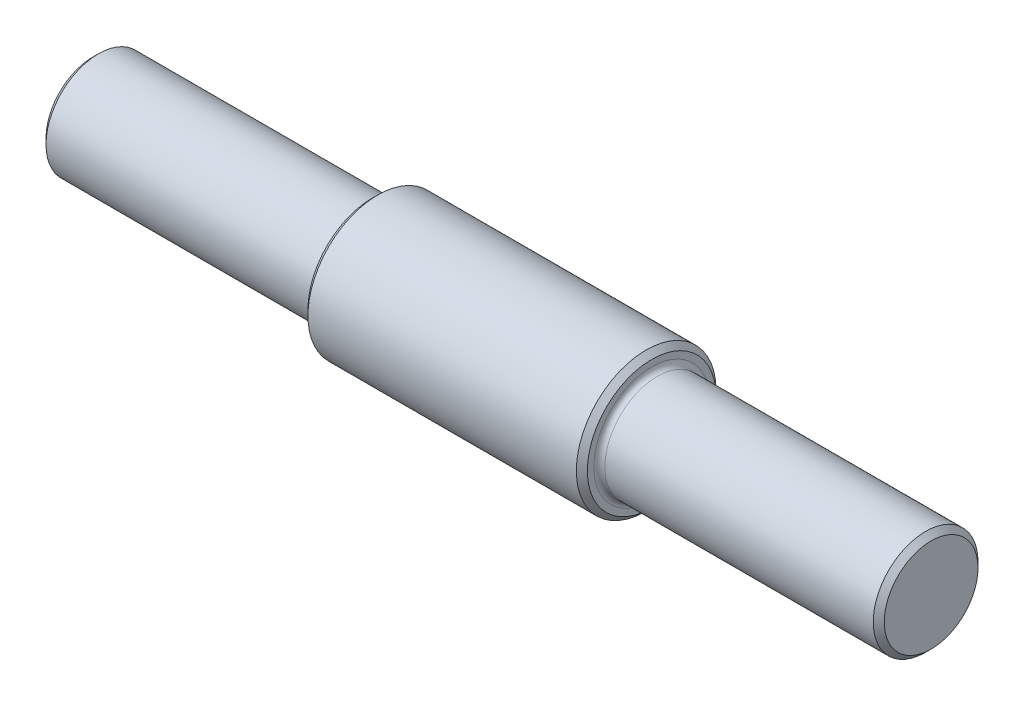
from build123d import *

# Parameters (mm, degrees)
CROQUIS1_R              = 12.7
SALIENTE_EXTRUIR1_DEPTH = 25.4
CROQUIS2_R              = 9.525
SALIENTE_EXTRUIR2_DEPTH = 50.8
REDONDEO1_R             = 1
REDONDEO2_R             = 1
CHAFL_N1_SIZE           = 1
CHAFL_N2_SIZE           = 1


with BuildPart() as part:
    # Croquis1 → Saliente-Extruir1 (new body, symmetric)
    with BuildSketch(Plane(origin=(0, 0, 0), x_dir=(0, 0, -1), z_dir=(1, 0, 0))):
        Circle(CROQUIS1_R)
    extrude(amount=SALIENTE_EXTRUIR1_DEPTH, both=True)

    # Croquis2 → Saliente-Extruir2 (add)
    with BuildSketch(Plane(origin=(25.4, 0, 0), x_dir=(0, 0, -1), z_dir=(1, 0, 0))):
        Circle(CROQUIS2_R)
    saliente_extruir2 = extrude(amount=SALIENTE_EXTRUIR2_DEPTH)

    # Redondeo1
    redondeo1_edges = [part.edges().sort_by_distance(p)[0] for p in [
        (25.4, 0, 9.525),
    ]]
    fillet(redondeo1_edges, radius=REDONDEO1_R)

    # Simetría3: Saliente-Extruir2 across plane
    add(saliente_extruir2.mirror(Plane(origin=(0, 0, 0), x_dir=(0, 0, 1), z_dir=(1, 0, 0))))

    # Redondeo2
    redondeo2_edges = [part.edges().sort_by_distance(p)[0] for p in [
        (-25.4, 0, 9.525),
    ]]
    fillet(redondeo2_edges, radius=REDONDEO2_R)

    # Chaflán1
    chafl_n1_edges = [part.edges().sort_by_distance(p)[0] for p in [
        (-76.2, 0, 9.525),
        (76.2, 0, 9.525),
    ]]
    chamfer(chafl_n1_edges, length=CHAFL_N1_SIZE)

    # Chaflán2
    chafl_n2_edges = [part.edges().sort_by_distance(p)[0] for p in [
        (-25.4, 0, 12.7),
        (25.4, 0, 12.7),
    ]]
    chamfer(chafl_n2_edges, length=CHAFL_N2_SIZE)


solid = part.part
